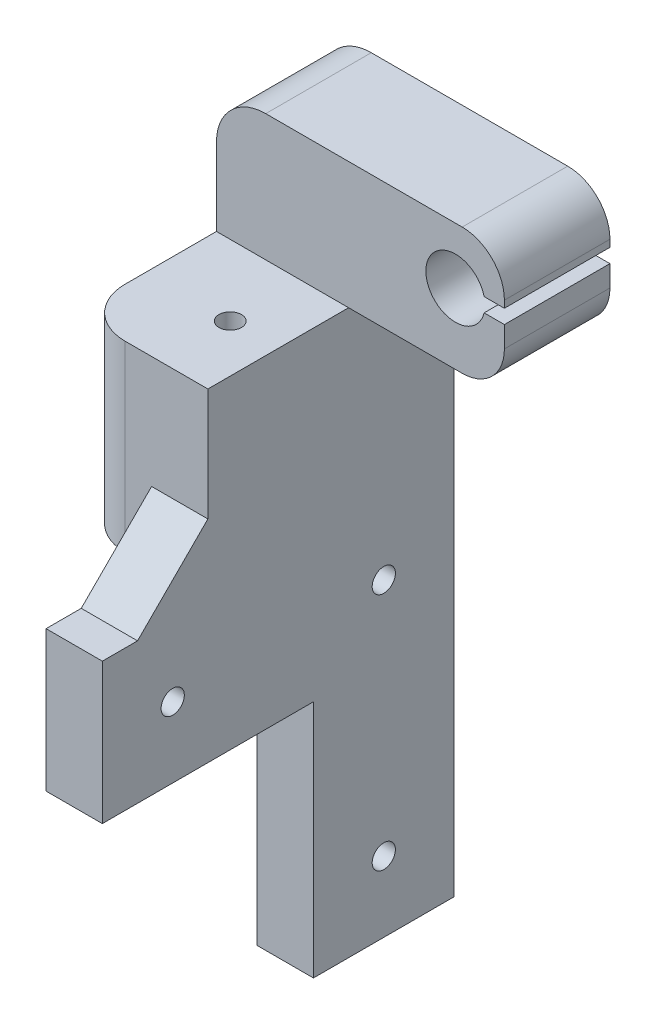
from build123d import *

# Parameters (mm, degrees)
EXTRUDE_1_DEPTH     = 15
SKETCH_2_W          = 18.78
SKETCH_2_H          = 26
EXTRUDE_2_DEPTH     = 20
SKETCH_3_W          = 8
SKETCH_3_H          = 54
EXTRUDE_3_DEPTH     = 5
SKETCH_4_W          = 8
SKETCH_4_H          = 20
EXTRUDE_4_DEPTH     = 30
CUT_EXTRUDE_2_DEPTH = 30
FILLET_1_R          = 6
FILLET_2_R          = 6
FILLET_3_R          = 7
FILLET_4_R          = 7
CHAMFER_1_SIZE      = 10
CHAMFER_2_SIZE      = 4
SKETCH_6_R          = 1.6
CUT_EXTRUDE_3_DEPTH = 179
SKETCH_9_W          = 20.537192292
SKETCH_9_H          = 20
CUT_EXTRUDE_4_DEPTH = 179
SKETCH_10_R         = 1.65
CUT_EXTRUDE_5_DEPTH = 179


with BuildPart() as part:
    # 草图1 → 凸台-拉伸1 (new body)
    with BuildSketch(Plane.XY):
        Polygon((0, 0), (8, 0), (8, 80), (30.14, 80), (30.14, 98), (-10.78, 98), (-10.78, 54), (0, 54), align=None)
    extrude(amount=EXTRUDE_1_DEPTH)

    # 草图2 → 凸台-拉伸2 (add)
    with BuildSketch(Plane.XY.offset(15)):
        with Locations((-1.39, 67)):
            Rectangle(SKETCH_2_W, SKETCH_2_H)
    extrude(amount=EXTRUDE_2_DEPTH)

    # 草图3 → 凸台-拉伸3 (add)
    with BuildSketch(Plane.XY.offset(15)):
        with Locations((4, 27)):
            Rectangle(SKETCH_3_W, SKETCH_3_H)
    extrude(amount=EXTRUDE_3_DEPTH)

    # 草图4 → 凸台-拉伸4 (add)
    with BuildSketch(Plane.XY.offset(20)):
        with Locations((4, 44)):
            Rectangle(SKETCH_4_W, SKETCH_4_H)
    extrude(amount=EXTRUDE_4_DEPTH)

    # 草图5 → 切除-拉伸2 (cut)
    with BuildSketch(Plane.XY.offset(15)):
        with BuildLine():
            Line((30.14, 90), (30.14, 91))
            Line((30.14, 91), (27.259215611, 91))
            ThreePointArc((27.259215611, 91), (18.98, 90), (27.259215611, 89))
            Line((27.259215611, 89), (30.14, 89))
            Line((30.14, 89), (30.14, 90))
        make_face()
    extrude(amount=-CUT_EXTRUDE_2_DEPTH, mode=Mode.SUBTRACT)

    # 圆角1
    fillet_1_edges = [part.edges().sort_by_distance(p)[0] for p in [
        (30.14, 98, 7.5),
    ]]
    fillet(fillet_1_edges, radius=FILLET_1_R)

    # 圆角2
    fillet_2_edges = [part.edges().sort_by_distance(p)[0] for p in [
        (30.14, 80, 7.5),
    ]]
    fillet(fillet_2_edges, radius=FILLET_2_R)

    # 圆角3
    fillet_3_edges = [part.edges().sort_by_distance(p)[0] for p in [
        (-10.78, 98, 7.5),
    ]]
    fillet(fillet_3_edges, radius=FILLET_3_R)

    # 圆角4
    fillet_4_edges = [part.edges().sort_by_distance(p)[0] for p in [
        (-10.78, 67, 35),
    ]]
    fillet(fillet_4_edges, radius=FILLET_4_R)

    # 倒角1
    chamfer_1_edges = [part.edges().sort_by_distance(p)[0] for p in [
        (4, 54, 35),
    ]]
    chamfer(chamfer_1_edges, length=CHAMFER_1_SIZE)

    # 倒角2
    chamfer_2_edges = [part.edges().sort_by_distance(p)[0] for p in [
        (0, 54, 17.5),
    ]]
    chamfer(chamfer_2_edges, length=CHAMFER_2_SIZE)

    # 草图6 → 切除-拉伸3 (cut)
    with BuildSketch(Plane(origin=(0, 80, 0), x_dir=(1, 0, 0), z_dir=(0, 1, 0))):
        with Locations((1.22, -25.05)):
            Circle(SKETCH_6_R)
    extrude(amount=-CUT_EXTRUDE_3_DEPTH, mode=Mode.SUBTRACT)

    # 草图9 → 切除-拉伸4 (cut)
    with BuildSketch(Plane.ZY):
        with Locations((30.268596146, 44)):
            Rectangle(SKETCH_9_W, SKETCH_9_H)
    extrude(amount=CUT_EXTRUDE_4_DEPTH, mode=Mode.SUBTRACT)

    # 草图10 → 切除-拉伸5 (cut)
    with BuildSketch(Plane.ZY):
        with Locations((40, 44)):
            Circle(SKETCH_10_R)
        with Locations((10, 10)):
            Circle(SKETCH_10_R)
        with Locations((10, 44)):
            Circle(SKETCH_10_R)
    extrude(amount=-CUT_EXTRUDE_5_DEPTH, mode=Mode.SUBTRACT)


solid = part.part
